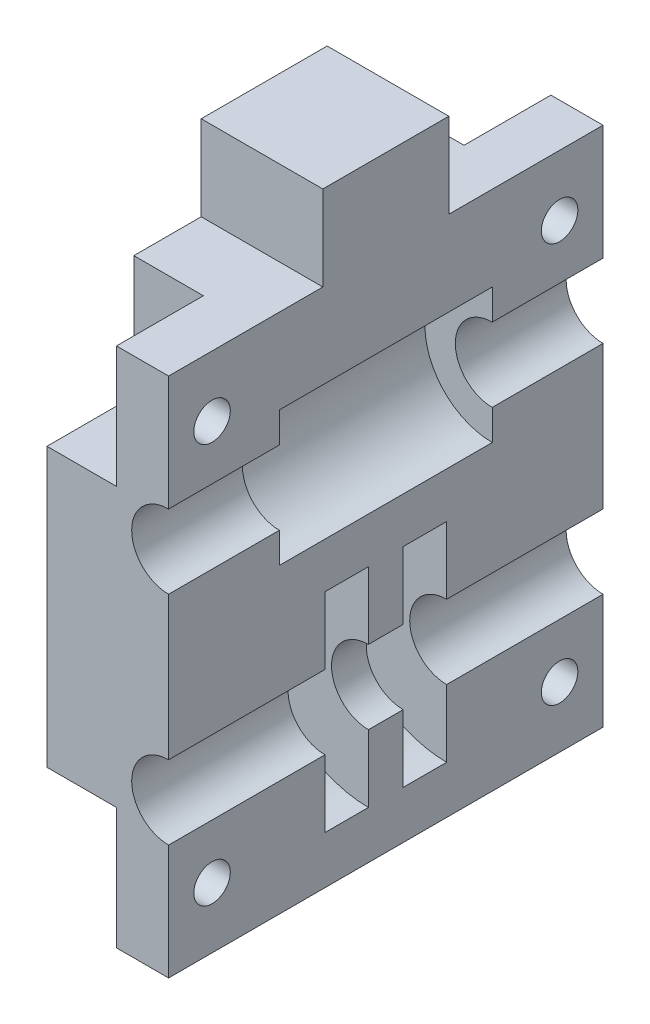
from build123d import *

# Parameters (mm, degrees)
BOSS_EXTRUDE1_DEPTH = 50
SKETCH2_R           = 7.75
CUT_EXTRUDE1_DEPTH  = 12.25
SKETCH4_R           = 12
CUT_EXTRUDE2_DEPTH  = 5
SKETCH5_W           = 10
SKETCH5_H           = 14
CUT_EXTRUDE3_DEPTH  = 8
SKETCH6_R           = 2.1
CUT_EXTRUDE4_DEPTH  = 7
SKETCH7_W           = 14
SKETCH7_H           = 14.5
BOSS_EXTRUDE2_DEPTH = 9.77


with BuildPart() as part:
    # Sketch1 → Boss-Extrude1 (new body)
    with BuildSketch(Plane.XY):
        with BuildLine():
            Line((-7, 30), (7, 30))
            Line((7, 30), (7, 16.75))
            ThreePointArc((7, 16.75), (2.75, 12.5), (7, 8.25))
            Line((7, 8.25), (7, -8.25))
            ThreePointArc((7, -8.25), (2.75, -12.5), (7, -16.75))
            Line((7, -16.75), (7, -30))
            Line((7, -30), (-7, -30))
            Line((-7, -30), (-7, 30))
        make_face()
    extrude(amount=BOSS_EXTRUDE1_DEPTH)

    # Sketch2 → Cut-Extrude1 (cut, symmetric)
    with BuildSketch(Plane(origin=(0, 0, 25), x_dir=(-1, 0, 0), z_dir=(0, 0, -1))):
        with Locations((-7, 12.5)):
            Circle(SKETCH2_R)
    extrude(amount=CUT_EXTRUDE1_DEPTH, both=True, mode=Mode.SUBTRACT)

    # Sketch4 → Cut-Extrude2 (cut)
    with BuildSketch(Plane(origin=(0, 0, 23), x_dir=(-1, 0, 0), z_dir=(0, 0, -1))):
        with Locations((-7, -12.5)):
            Circle(SKETCH4_R)
    cut_extrude2 = extrude(amount=CUT_EXTRUDE2_DEPTH, mode=Mode.SUBTRACT)

    # Mirror1: Cut-Extrude2 across plane
    add(cut_extrude2.mirror(Plane(origin=(0, 0, 25), x_dir=(1, 0, 0), z_dir=(0, 0, -1))), mode=Mode.SUBTRACT)

    # Sketch5 → Cut-Extrude3 (cut)
    with BuildSketch(Plane.ZY.offset(7)):
        with Locations((5, 23)):
            Rectangle(SKETCH5_W, SKETCH5_H)
        with Locations((45, 23)):
            Rectangle(SKETCH5_W, SKETCH5_H)
        with Locations((45, -23)):
            Rectangle(SKETCH5_W, SKETCH5_H)
        with Locations((5, -23)):
            Rectangle(SKETCH5_W, SKETCH5_H)
    extrude(amount=-CUT_EXTRUDE3_DEPTH, mode=Mode.SUBTRACT)

    # Sketch6 → Cut-Extrude4 (cut, through all)
    with BuildSketch(Plane.ZY.offset(-1)):
        with Locations((5, 23)):
            Circle(SKETCH6_R)
        with Locations((45, 23)):
            Circle(SKETCH6_R)
        with Locations((5, -23)):
            Circle(SKETCH6_R)
        with Locations((45, -23)):
            Circle(SKETCH6_R)
    extrude(amount=-CUT_EXTRUDE4_DEPTH, mode=Mode.SUBTRACT)

    # Sketch7 → Boss-Extrude2 (add)
    with BuildSketch(Plane(origin=(0, 30, 0), x_dir=(1, 0, 0), z_dir=(0, 1, 0))):
        with Locations((0, -25)):
            Rectangle(SKETCH7_W, SKETCH7_H)
    extrude(amount=BOSS_EXTRUDE2_DEPTH)


solid = part.part
